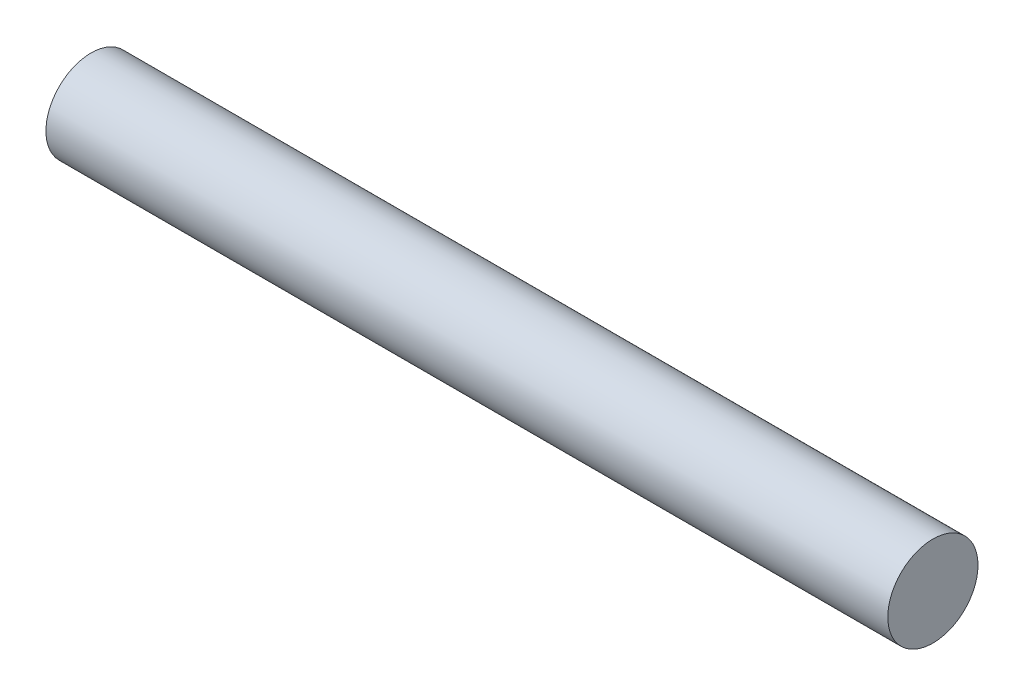
from build123d import *

# Parameters (mm, degrees)
CROQUIS2_R = 9.525


with BuildPart() as part:
    # Barrer1: sweep along a path in Croquis1
    with BuildLine(Plane.XY) as barrer1_path:
        Line((0, 0), (177.8, 0))
    # Croquis2 → Barrer1 (sweep)
    with BuildSketch(Plane(origin=(0, 0, 0), x_dir=(0, 0, -1), z_dir=(1, 0, 0))):
        Circle(CROQUIS2_R)
    sweep(path=barrer1_path.line)


solid = part.part
